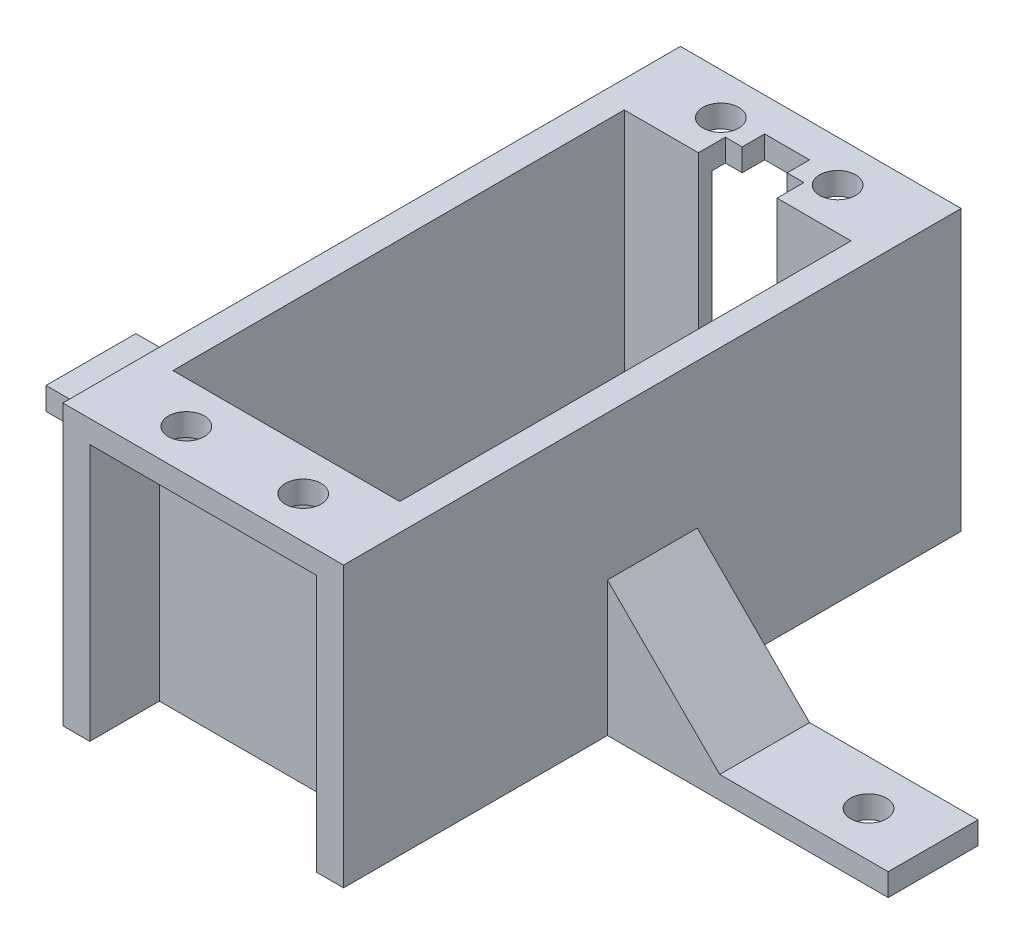
from build123d import *

# Parameters (mm, degrees)
SKETCH2_W           = 75
SKETCH2_H           = 8
SKETCH2_R           = 1.6
BOSS_EXTRUDE1_DEPTH = 2
SKETCH3_W           = 25
SKETCH3_H           = 18.5
BOSS_EXTRUDE2_DEPTH = 2
SKETCH4_W           = 25
SKETCH4_H           = 2
BOSS_EXTRUDE3_DEPTH = 18.5
SKETCH5_W           = 10.2
SKETCH5_H           = 40.2
CUT_EXTRUDE1_DEPTH  = 18.5
SKETCH6_W           = 10.2
SKETCH6_H           = 40.2
BOSS_EXTRUDE4_DEPTH = 24.9
SKETCH8_W           = 25
SKETCH8_H           = 7
BOSS_EXTRUDE5_DEPTH = 2
SKETCH9_R           = 1.6
CUT_EXTRUDE2_DEPTH  = 2
SKETCH10_W          = 20.2
SKETCH10_H          = 40.2
CUT_EXTRUDE3_DEPTH  = 77
SKETCH11_W          = 7
SKETCH11_H          = 2.4
CUT_EXTRUDE4_DEPTH  = 77
SKETCH12_W          = 2.4
SKETCH12_H          = 7
BOSS_EXTRUDE6_DEPTH = 24.9
SKETCH13_W          = 4
SKETCH13_H          = 4
CUT_EXTRUDE5_DEPTH  = 77
SKETCH14_W          = 25
SKETCH14_H          = 8
SKETCH14_R          = 1.6
BOSS_EXTRUDE7_DEPTH = 2
CUT_EXTRUDE6_DEPTH  = 2
CHAMFER1_SIZE       = 10
CUT_EXTRUDE7_DEPTH  = 1.2
SKETCH17_W          = 20.2
SKETCH17_H          = 22.9
CUT_EXTRUDE8_DEPTH  = 1.2
CUT_EXTRUDE9_DEPTH  = 2
CUT_EXTRUDE10_DEPTH = 2


with BuildPart() as part:
    # Sketch2 → Boss-Extrude1 (new body)
    with BuildSketch(Plane(origin=(0, 0, 0), x_dir=(1, 0, 0), z_dir=(0, 1, 0))):
        Rectangle(SKETCH2_W, SKETCH2_H)
        with Locations((-31.75, 0)):
            Circle(SKETCH2_R, mode=Mode.SUBTRACT)
        with Locations((31.75, 0)):
            Circle(SKETCH2_R, mode=Mode.SUBTRACT)
    extrude(amount=BOSS_EXTRUDE1_DEPTH)

    # Sketch3 → Boss-Extrude2 (add)
    with BuildSketch(Plane(origin=(0, 2, 0), x_dir=(1, 0, 0), z_dir=(0, 1, 0))):
        with Locations((0, -13.25)):
            Rectangle(SKETCH3_W, SKETCH3_H)
    extrude(amount=-BOSS_EXTRUDE2_DEPTH)

    # Sketch4 → Boss-Extrude3 (add)
    with BuildSketch(Plane(origin=(0, 0, -4), x_dir=(-1, 0, 0), z_dir=(0, 0, -1))):
        with Locations((0, 1)):
            Rectangle(SKETCH4_W, SKETCH4_H)
    extrude(amount=BOSS_EXTRUDE3_DEPTH)

    # Sketch5 → Cut-Extrude1 (cut)
    with BuildSketch(Plane(origin=(0, 2, 0), x_dir=(1, 0, 0), z_dir=(0, 1, 0))):
        Rectangle(SKETCH5_W, SKETCH5_H)
    extrude(amount=-CUT_EXTRUDE1_DEPTH, mode=Mode.SUBTRACT)

    # Sketch6 → Boss-Extrude4 (add)
    with BuildSketch(Plane(origin=(0, 2, 0), x_dir=(1, 0, 0), z_dir=(0, 1, 0))):
        Polygon((-12.5, 4), (-12.5, -4), (-12.5, -22.5), (12.5, -22.5), (12.5, -4), (12.5, 4), (12.5, 22.5), (-12.5, 22.5), align=None)
        Rectangle(SKETCH6_W, SKETCH6_H, mode=Mode.SUBTRACT)
    extrude(amount=BOSS_EXTRUDE4_DEPTH)

    # Sketch8 → Boss-Extrude5 (add)
    with BuildSketch(Plane(origin=(0, 26.9, 0), x_dir=(1, 0, 0), z_dir=(0, 1, 0))):
        with Locations((0, 26)):
            Rectangle(SKETCH8_W, SKETCH8_H)
        with Locations((0, -26)):
            Rectangle(SKETCH8_W, SKETCH8_H)
    extrude(amount=-BOSS_EXTRUDE5_DEPTH)

    # Sketch9 → Cut-Extrude2 (cut)
    with BuildSketch(Plane.XZ.offset(-24.9)):
        with Locations((5.2, 23.8)):
            Circle(SKETCH9_R)
        with Locations((-5.2, 23.8)):
            Circle(SKETCH9_R)
        with Locations((-5.2, -23.8)):
            Circle(SKETCH9_R)
        with Locations((5.2, -23.8)):
            Circle(SKETCH9_R)
    extrude(amount=-CUT_EXTRUDE2_DEPTH, mode=Mode.SUBTRACT)

    # Sketch10 → Cut-Extrude3 (cut)
    with BuildSketch(Plane.XZ):
        Rectangle(SKETCH10_W, SKETCH10_H)
    extrude(amount=-CUT_EXTRUDE3_DEPTH, mode=Mode.SUBTRACT)

    # Sketch11 → Cut-Extrude4 (cut)
    with BuildSketch(Plane.XZ):
        with Locations((0, -21.3)):
            Rectangle(SKETCH11_W, SKETCH11_H)
    extrude(amount=-CUT_EXTRUDE4_DEPTH, mode=Mode.SUBTRACT)

    # Sketch12 → Boss-Extrude6 (add)
    with BuildSketch(Plane.XZ):
        with Locations((-11.3, 26)):
            Rectangle(SKETCH12_W, SKETCH12_H)
        with Locations((-11.3, -26)):
            Rectangle(SKETCH12_W, SKETCH12_H)
        with Locations((11.3, 26)):
            Rectangle(SKETCH12_W, SKETCH12_H)
        with Locations((11.3, -26)):
            Rectangle(SKETCH12_W, SKETCH12_H)
    extrude(amount=-BOSS_EXTRUDE6_DEPTH)

    # Sketch13 → Cut-Extrude5 (cut)
    with BuildSketch(Plane(origin=(0, 26.9, 0), x_dir=(1, 0, 0), z_dir=(0, 1, 0))):
        with Locations((0, 22.5)):
            Rectangle(SKETCH13_W, SKETCH13_H)
    extrude(amount=-CUT_EXTRUDE5_DEPTH, mode=Mode.SUBTRACT)

    # Sketch14 → Boss-Extrude7 (add)
    with BuildSketch(Plane(origin=(0, 2, 0), x_dir=(1, 0, 0), z_dir=(0, 1, 0))):
        with Locations((-25, 0)):
            Rectangle(SKETCH14_W, SKETCH14_H)
        with Locations((-31.75, 0)):
            Circle(SKETCH14_R, mode=Mode.SUBTRACT)
        with Locations((25, 0)):
            Rectangle(SKETCH14_W, SKETCH14_H)
        with Locations((31.75, 0)):
            Circle(SKETCH14_R, mode=Mode.SUBTRACT)
    extrude(amount=BOSS_EXTRUDE7_DEPTH)

    # Sketch15 → Cut-Extrude6 (cut)
    with BuildSketch(Plane.XZ):
        Polygon((10.1, -20.1), (3.5, -20.1), (3.5, -22.5), (10.1, -22.5), (10.1, -29.5), (12.5, -29.5), (12.5, -4), (37.5, -4), (37.5, 4), (12.5, 4), (12.5, 29.5), (10.1, 29.5), (10.1, 22.5), (-10.1, 22.5), (-10.1, 29.5), (-12.5, 29.5), (-12.5, 4), (-37.5, 4), (-37.5, -4), (-12.5, -4), (-12.5, -29.5), (-10.1, -29.5), (-10.1, -22.5), (-3.5, -22.5), (-3.5, -20.1), (-10.1, -20.1), (-10.1, 20.1), (10.1, 20.1), align=None)
    extrude(amount=-CUT_EXTRUDE6_DEPTH, mode=Mode.SUBTRACT)

    # Chamfer1
    chamfer1_edges = [part.edges().sort_by_distance(p)[0] for p in [
        (-12.5, 4, 0),
        (12.5, 4, 0),
    ]]
    chamfer(chamfer1_edges, length=CHAMFER1_SIZE)

    # Sketch16 → Cut-Extrude7 (cut)
    with BuildSketch(Plane.XY.offset(22.5)):
        Polygon((-10.1, 2), (10.1, 2), (10.1, 24.9), (6.132737905, 24.9), (4.267262095, 24.9), (-4.267262095, 24.9), (-6.132737905, 24.9), (-10.1, 24.9), align=None)
    extrude(amount=-CUT_EXTRUDE7_DEPTH, mode=Mode.SUBTRACT)

    # Sketch17 → Cut-Extrude8 (cut)
    with BuildSketch(Plane(origin=(0, 0, -22.5), x_dir=(-1, 0, 0), z_dir=(0, 0, -1))):
        with Locations((0, 13.45)):
            Rectangle(SKETCH17_W, SKETCH17_H)
    extrude(amount=-CUT_EXTRUDE8_DEPTH, mode=Mode.SUBTRACT)

    # Sketch18 → Cut-Extrude9 (cut)
    with BuildSketch(Plane(origin=(0, 0, -29.5), x_dir=(-1, 0, 0), z_dir=(0, 0, -1))):
        Polygon((10.1, 2), (12.5, 2), (12.5, 26.9), (-12.5, 26.9), (-12.5, 2), (-10.1, 2), (-10.1, 24.9), (10.1, 24.9), align=None)
    extrude(amount=-CUT_EXTRUDE9_DEPTH, mode=Mode.SUBTRACT)

    # Sketch19 → Cut-Extrude10 (cut)
    with BuildSketch(Plane.XY.offset(29.5)):
        Polygon((10.1, 2), (12.5, 2), (12.5, 26.9), (-12.5, 26.9), (-12.5, 2), (-10.1, 2), (-10.1, 24.9), (10.1, 24.9), align=None)
    extrude(amount=-CUT_EXTRUDE10_DEPTH, mode=Mode.SUBTRACT)


solid = part.part
